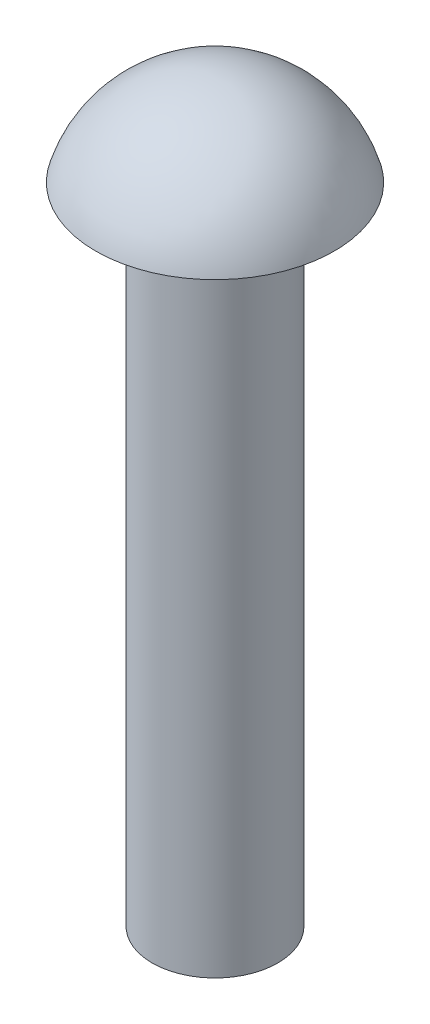
from build123d import *


with BuildPart() as part:
    # Sketch1 → Revolve2 (revolve)
    with BuildSketch(Plane(origin=(0, 0, 0), x_dir=(0, 0, -1), z_dir=(1, 0, 0))):
        with BuildLine():
            Line((0, -11.4), (0.975, -11.4))
            Line((0.975, -11.4), (0.975, -1.4))
            Line((0.975, -1.4), (1.85, -1.4))
            ThreePointArc((1.85, -1.4), (1.160010776, -0.389450046), (0, 0))
            Line((0, 0), (0, -11.4))
        make_face()
    revolve(axis=Axis((0, 0, 0), (0, -1, 0)))


solid = part.part
